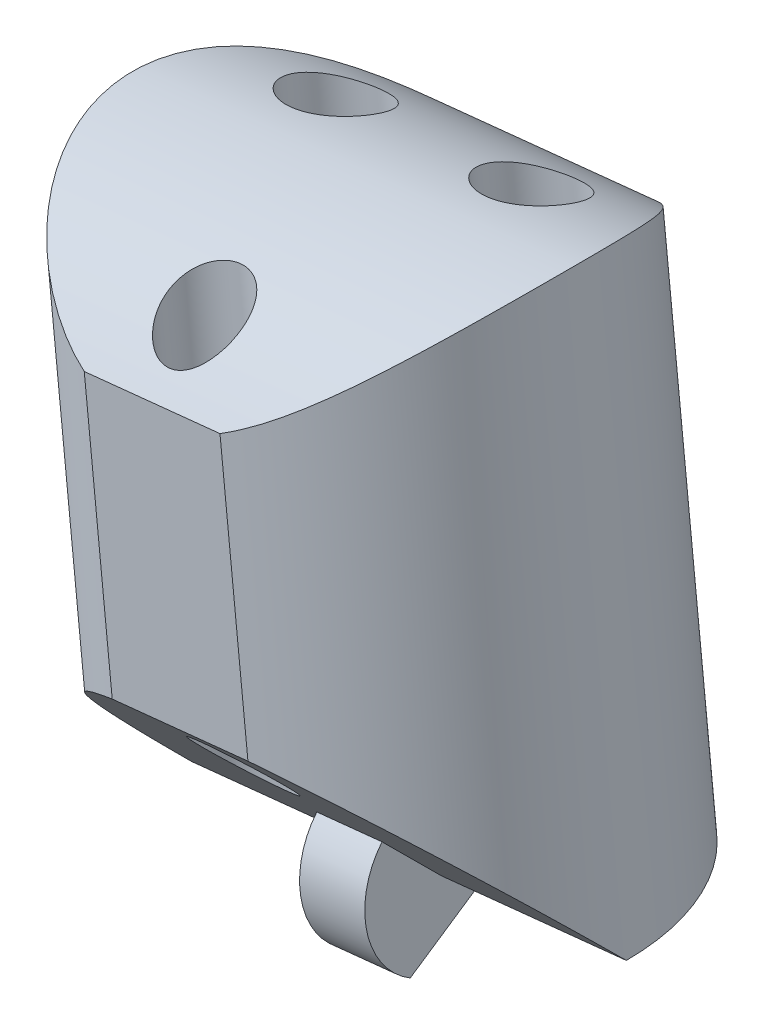
from build123d import *

# Parameters (mm, degrees)
SKETCH3_R               = 8
BOSS_EXTRUDE1_DEPTH     = 21.052631579
CUT_EXTRUDE1_DEPTH      = 11.160006171
CUT_EXTRUDE1_DEPTH_BACK = 11.160006171
CUT_EXTRUDE2_DEPTH      = 11.146902499
CUT_EXTRUDE2_DEPTH_BACK = 11.1469025
BOSS_EXTRUDE3_DEPTH     = 1.2
SKETCH8_R               = 1.6
SKETCH8_R_2             = 1.4
CUT_EXTRUDE3_DEPTH      = 25.395624714
CUT_EXTRUDE3_DEPTH_BACK = 2.513887999
CUT_EXTRUDE4_DEPTH      = 23.566519578


with BuildPart() as part:
    # Sketch3 → Boss-Extrude1 (new body)
    with BuildSketch(Plane(origin=(-12.082314344, 217.636022384, 0), x_dir=(-0.994665758, -0.103150523, 0), z_dir=(0.103150523, -0.994665758, 0))):
        Circle(SKETCH3_R)
    extrude(amount=BOSS_EXTRUDE1_DEPTH)

    # Sketch4 → Cut-Extrude1 (cut, two sides)
    with BuildSketch(Plane(origin=(10.375761543, 1.076004901, 0), x_dir=(0.103150523, -0.994665758, 0), z_dir=(-0.994665758, -0.103150523, 0))) as cut_extrude1_sk:
        with BuildLine():
            Line((-217.721396158, 8), (-213.721396158, 8))
            ThreePointArc((-213.721396158, 8), (-217.59367935, 0), (-213.721396158, -8))
            Line((-213.721396158, -8), (-217.721396158, -8))
            Line((-217.721396158, -8), (-217.721396158, 8))
        make_face()
    extrude(amount=CUT_EXTRUDE1_DEPTH, mode=Mode.SUBTRACT)
    extrude(cut_extrude1_sk.sketch, amount=-CUT_EXTRUDE1_DEPTH_BACK, mode=Mode.SUBTRACT)

    # Sketch5 → Cut-Extrude2 (cut, two sides)
    with BuildSketch(Plane(origin=(10.375761543, 1.076004901, 0), x_dir=(0.103150523, -0.994665758, 0), z_dir=(-0.994665758, -0.103150523, 0))) as cut_extrude2_sk:
        Polygon((-196.668764579, 0), (-204.668764579, 8), (-196.668764579, 8), align=None)
    extrude(amount=CUT_EXTRUDE2_DEPTH, mode=Mode.SUBTRACT)
    extrude(cut_extrude2_sk.sketch, amount=-CUT_EXTRUDE2_DEPTH_BACK, mode=Mode.SUBTRACT)

    # Sketch7 → Boss-Extrude3 (add, symmetric)
    with BuildSketch(Plane(origin=(10.375761543, 1.076004901, 0), x_dir=(0.103150523, -0.994665758, 0), z_dir=(-0.994665758, -0.103150523, 0))):
        with BuildLine():
            Line((-198.648663566, 1.979898987), (-196.668764579, 0))
            Line((-196.668764579, 0), (-196.668764579, -2.8))
            Line((-196.668764579, -2.8), (-194.243893448, 1.4))
            ThreePointArc((-194.243893448, 1.4), (-196.303291241, 2.776045612), (-198.648663566, 1.979898987))
        make_face()
    extrude(amount=BOSS_EXTRUDE3_DEPTH, both=True)

    # Sketch8 → Cut-Extrude3 (cut, two sides)
    with BuildSketch(Plane(origin=(-12.082314344, 217.636022384, 0), x_dir=(-0.994665758, -0.103150523, 0), z_dir=(0.103150523, -0.994665758, 0))) as cut_extrude3_sk:
        with Locations((-3.6, 3)):
            Circle(SKETCH8_R)
        with Locations((3.6, 3)):
            Circle(SKETCH8_R)
        with Locations((0, -5.5)):
            Circle(SKETCH8_R_2)
    extrude(amount=CUT_EXTRUDE3_DEPTH, mode=Mode.SUBTRACT)
    extrude(cut_extrude3_sk.sketch, amount=-CUT_EXTRUDE3_DEPTH_BACK, mode=Mode.SUBTRACT)

    # Sketch9 → Cut-Extrude4 (cut, through all)
    with BuildSketch(Plane(origin=(-20.286485929, 195.619685742, 0), x_dir=(0.994665758, 0.103150523, 0), z_dir=(0.103150523, -0.994665758, 0))):
        with BuildLine():
            Line((7.933405986, -7.6), (12.929404385, -7.6))
            ThreePointArc((12.929404385, -7.6), (10.431405186, -8), (7.933405986, -7.6))
        make_face()
        with BuildLine():
            Line((7.933405986, 7.6), (12.929404385, 7.6))
            ThreePointArc((12.929404385, 7.6), (10.431405186, 8), (7.933405986, 7.6))
        make_face()
    extrude(amount=-CUT_EXTRUDE4_DEPTH, mode=Mode.SUBTRACT)


solid = part.part
